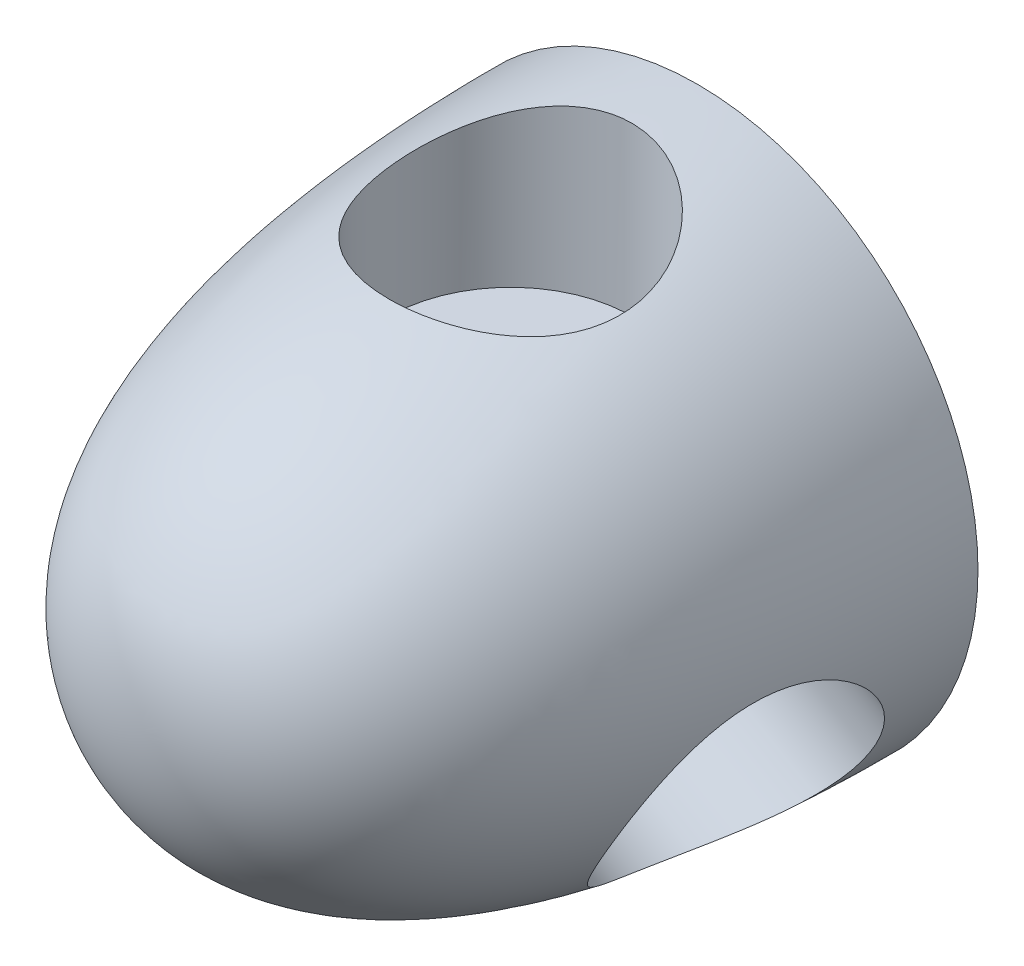
from build123d import *

# Parameters (mm, degrees)
SKETCH2_R          = 4.826
CUT_EXTRUDE1_DEPTH = 12.7
SKETCH5_R          = 8.255
CUT_EXTRUDE2_DEPTH = 11.356302
CIRPATTERN1_COUNT  = 3


with BuildPart() as part:
    # Sketch1 → Revolve1 (revolve)
    with BuildSketch(Plane(origin=(0, 0, 0), x_dir=(0, 0, -1), z_dir=(1, 0, 0))):
        with BuildLine():
            Line((0, 0), (38.1, 0))
            Line((38.1, 0), (38.1, 19.05))
            add(Edge.make_bspline(
                [(0, 0), (0, 16.933744176), (23.900968343, 19.05), (38.1, 19.05)],
                knots=[0, 0, 0, 0, 1, 1, 1, 1], degree=3))
        make_face()
    revolve(axis=Axis((0, 0, 26.403509965), (0, 0, -1)))

    # Sketch2 → Cut-Extrude1 (cut)
    with BuildSketch(Plane(origin=(0, 0, -38.1), x_dir=(-1, 0, 0), z_dir=(0, 0, -1))):
        Circle(SKETCH2_R)
    extrude(amount=-CUT_EXTRUDE1_DEPTH, mode=Mode.SUBTRACT)

    # Sketch5 → Cut-Extrude2 (cut)
    with BuildSketch(Plane(origin=(0, 7.62, 0), x_dir=(1, 0, 0), z_dir=(0, 1, 0))):
        with Locations((0, 25.4)):
            Circle(SKETCH5_R)
    cut_extrude2 = extrude(amount=CUT_EXTRUDE2_DEPTH, mode=Mode.SUBTRACT)

    # CirPattern1: Cut-Extrude2 ×3 about axis
    cirpattern1_axis = Axis((0, 0, 0), (0, 0, 1))
    for i in range(1, CIRPATTERN1_COUNT):
        add(cut_extrude2.rotate(cirpattern1_axis, i * 360 / CIRPATTERN1_COUNT), mode=Mode.SUBTRACT)


solid = part.part
